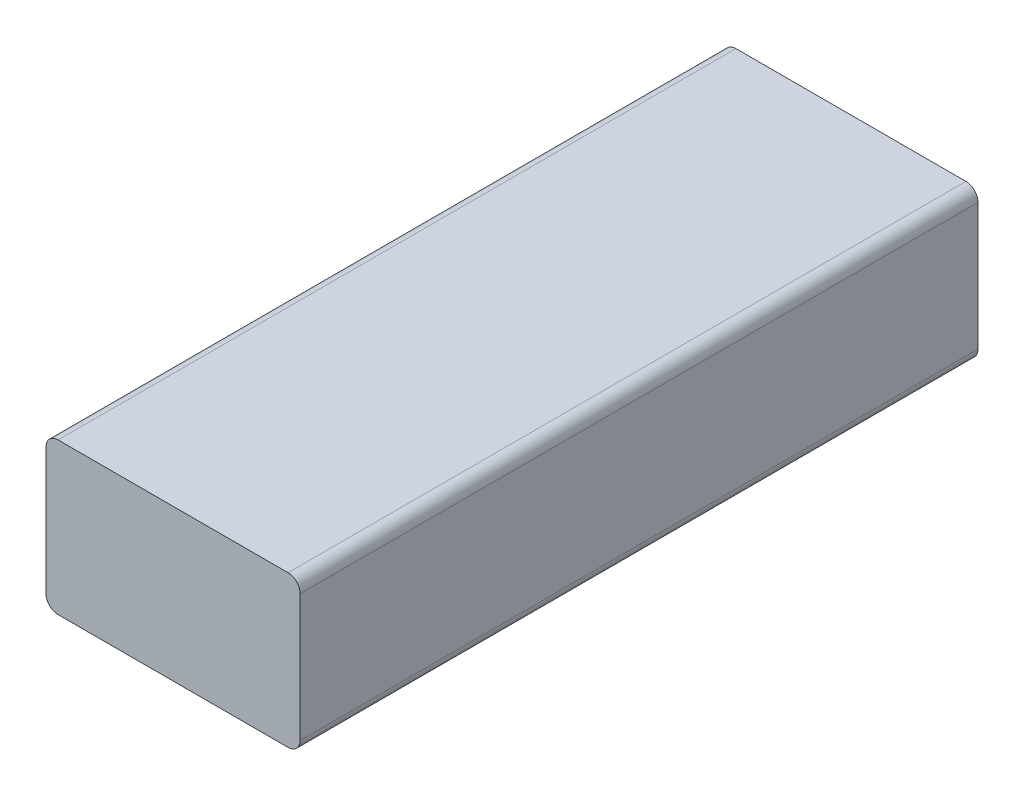
from build123d import *

# Parameters (mm, degrees)
SKETCH1_W           = 42
SKETCH1_H           = 25
BOSS_EXTRUDE1_DEPTH = 112
FILLET1_R           = 2


with BuildPart() as part:
    # Sketch1 → Boss-Extrude1 (new body)
    with BuildSketch(Plane.XY):
        with Locations((-8.340277778, 3.385416667)):
            Rectangle(SKETCH1_W, SKETCH1_H)
    extrude(amount=-BOSS_EXTRUDE1_DEPTH)

    # Fillet1
    fillet1_edges = [part.edges().sort_by_distance(p)[0] for p in [
        (-29.340277778, 15.885416667, -56),
        (12.659722222, 15.885416667, -56),
        (12.659722222, -9.114583333, -56),
        (-29.340277778, -9.114583333, -56),
    ]]
    fillet(fillet1_edges, radius=FILLET1_R)


solid = part.part
